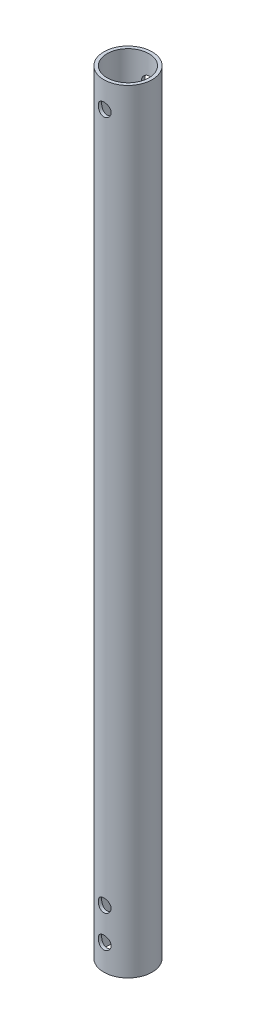
from build123d import *

# Parameters (mm, degrees)
SKETCH1_R           = 7.5
SKETCH1_R_2         = 6.5
BOSS_EXTRUDE1_DEPTH = 240
SKETCH2_R           = 2
CUT_EXTRUDE1_DEPTH  = 9


with BuildPart() as part:
    # Sketch1 → Boss-Extrude1 (new body)
    with BuildSketch(Plane(origin=(0, 0, 0), x_dir=(1, 0, 0), z_dir=(0, 1, 0))):
        Circle(SKETCH1_R)
        Circle(SKETCH1_R_2, mode=Mode.SUBTRACT)
    extrude(amount=BOSS_EXTRUDE1_DEPTH)

    # Sketch2 → Cut-Extrude1 (cut, symmetric)
    with BuildSketch(Plane.XY):
        with Locations((0, 8)):
            Circle(SKETCH2_R)
        with Locations((0, 18)):
            Circle(SKETCH2_R)
        with Locations((0, 242)):
            Circle(SKETCH2_R)
        with Locations((0, 232)):
            Circle(SKETCH2_R)
    extrude(amount=CUT_EXTRUDE1_DEPTH, both=True, mode=Mode.SUBTRACT)


solid = part.part
